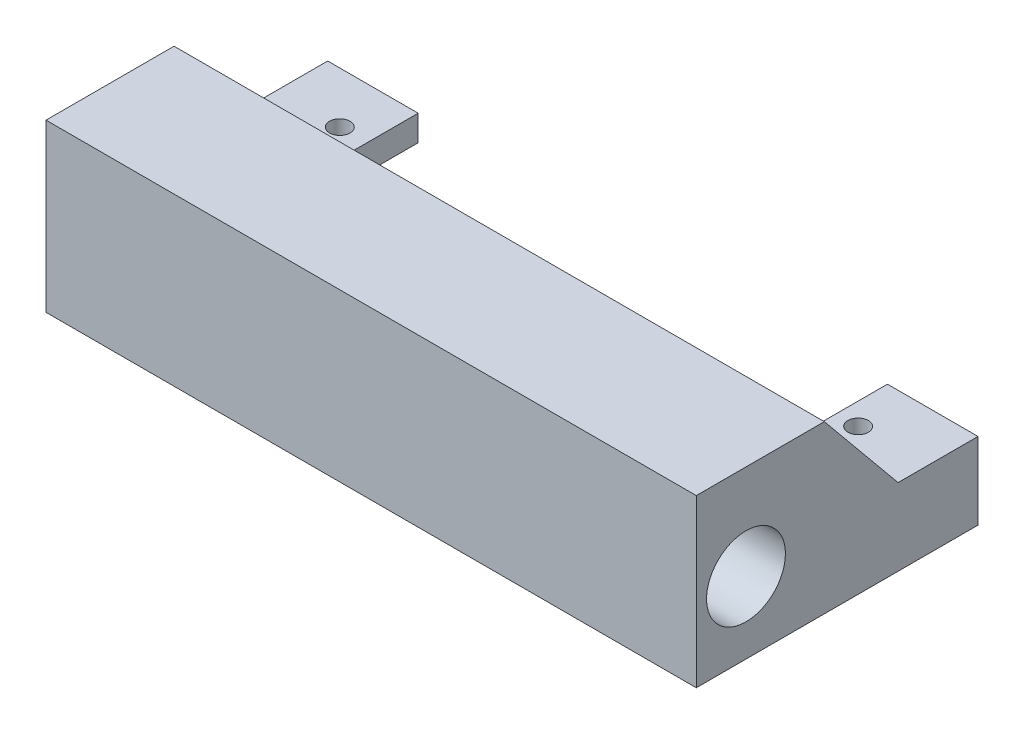
from build123d import *
from build123d.topology import SkipClean

# Parameters (mm, degrees)
SALIENTE_EXTRUIR1_DEPTH  = 5
SALIENTE_EXTRUIR3_DEPTH  = 5
SALIENTE_EXTRUIR4_DEPTH  = 12.5
CROQUIS2_W               = 12.6
CROQUIS2_H               = 5
CORTAR_EXTRUIR1_DEPTH    = 127.5
CROQUIS3_W               = 4.8
CROQUIS3_H               = 5
CORTAR_EXTRUIR2_DEPTH    = 255
CROQUIS4_W               = 116.76
CROQUIS4_H               = 32.5
SALIENTE_EXTRUIR5_DEPTH  = 25
CROQUIS5_R               = 4.5
CORTAR_EXTRUIR3_DEPTH    = 155
CROQUIS6_R               = 7.7
CORTAR_EXTRUIR4_DEPTH    = 20.3
CROQUIS7_R               = 7.7
SALIENTE_EXTRUIR6_DEPTH  = 5
CORTAR_EXTRUIR5_DEPTH    = 25.2
CROQUIS9_W               = 1
CROQUIS9_H               = 10
CORTAR_EXTRUIR6_DEPTH    = 4.8
CROQUIS10_W              = 117.76
CROQUIS10_H              = 0.4
CORTAR_EXTRUIR7_DEPTH    = 10
CROQUIS11_R              = 2
CORTAR_EXTRUIR8_DEPTH    = 10
CROQUIS12_W              = 3
CROQUIS12_H              = 7.5
CORTAR_EXTRUIR9_DEPTH    = 220
CORTAR_EXTRUIR10_DEPTH   = 220
SALIENTE_EXTRUIR7_DEPTH  = 16.68
SALIENTE_EXTRUIR8_START  = 1
CROQUIS15_R              = 7.7
SALIENTE_EXTRUIR8_DEPTH  = 1
SALIENTE_EXTRUIR9_START  = 1.8
CROQUIS16_R              = 7.7
CROQUIS16_R_2            = 4.5
SALIENTE_EXTRUIR9_DEPTH  = 1.8
SALIENTE_EXTRUIR10_DEPTH = 1
CROQUIS18_W              = 0.78
CROQUIS18_H              = 5
SALIENTE_EXTRUIR11_DEPTH = 31
SALIENTE_EXTRUIR12_DEPTH = 0.78
CORTAR_EXTRUIR11_DEPTH   = 220.78
CROQUIS21_R              = 2
CORTAR_EXTRUIR12_DEPTH   = 220.78
CROQUIS22_W              = 0.2
CROQUIS22_H              = 10
SALIENTE_EXTRUIR13_DEPTH = 30.78


with BuildPart() as part:
    # Croquis1 → Saliente-Extruir1 (new body)
    with BuildSketch(Plane(origin=(0, 0, 0), x_dir=(1, 0, 0), z_dir=(0, 1, 0))):
        Polygon((-45.7, 25.2), (-58.38, 25.2), (-58.38, -4.8), (58.38, -4.8), (58.38, 25.2), (45.7, 25.2), (45.7, 0), (-45.7, 0), align=None)
    extrude(amount=SALIENTE_EXTRUIR1_DEPTH)

    # Croquis1_4 → Saliente-Extruir3 (add)
    with BuildSketch(Plane(origin=(0, 0, 0), x_dir=(1, 0, 0), z_dir=(0, 1, 0))):
        Polygon((-45.7, 12.6), (-58.38, 12.6), (-58.38, -4.8), (58.38, -4.8), (58.38, 12.6), (45.7, 12.6), (45.7, 0), (-45.7, 0), align=None)
    extrude(amount=-SALIENTE_EXTRUIR3_DEPTH)

    # Croquis1_5 → Saliente-Extruir4 (add)
    with BuildSketch(Plane(origin=(0, 0, 0), x_dir=(1, 0, 0), z_dir=(0, 1, 0))):
        Polygon((-45.7, 12.6), (-58.38, 12.6), (-58.38, -4.8), (58.38, -4.8), (58.38, 12.6), (45.7, 12.6), (45.7, 0), (-45.7, 0), align=None)
    extrude(amount=SALIENTE_EXTRUIR4_DEPTH)

    # Croquis2 → Cortar-Extruir1 (cut, symmetric)
    with BuildSketch(Plane.ZY.offset(-45.7)):
        with Locations((-6.3, -2.5)):
            Rectangle(CROQUIS2_W, CROQUIS2_H)
    extrude(amount=CORTAR_EXTRUIR1_DEPTH, both=True, mode=Mode.SUBTRACT)

    # Croquis3 → Cortar-Extruir2 (cut)
    with BuildSketch(Plane.ZY.offset(58.38)):
        with Locations((2.4, -2.5)):
            Rectangle(CROQUIS3_W, CROQUIS3_H)
    extrude(amount=-CORTAR_EXTRUIR2_DEPTH, mode=Mode.SUBTRACT)

    # Croquis4 → Saliente-Extruir5 (add)
    with BuildSketch(Plane.XY.offset(4.8)):
        with Locations((0, 6.25)):
            Rectangle(CROQUIS4_W, CROQUIS4_H)
    extrude(amount=SALIENTE_EXTRUIR5_DEPTH)

    # Croquis5 → Cortar-Extruir3 (cut)
    with BuildSketch(Plane.ZY.offset(58.38)):
        with Locations((20.1, 4)):
            Circle(CROQUIS5_R)
    extrude(amount=-CORTAR_EXTRUIR3_DEPTH, mode=Mode.SUBTRACT)

    # Croquis6 → Cortar-Extruir4 (cut)
    with BuildSketch(Plane.ZY.offset(58.38)):
        with Locations((20.1, 4)):
            Circle(CROQUIS6_R)
    cortar_extruir4 = extrude(amount=-CORTAR_EXTRUIR4_DEPTH, mode=Mode.SUBTRACT)

    # Simetría1: Cortar-Extruir4 across plane
    add(cortar_extruir4.mirror(Plane(origin=(0, 0, 0), x_dir=(0, 0, 1), z_dir=(1, 0, 0))), mode=Mode.SUBTRACT)

    # Croquis7 → Saliente-Extruir6 (add)
    with BuildSketch(Plane.ZY.offset(58.38)):
        Polygon((-25.2, 5), (-25.2, -10), (29.8, -10), (29.8, 22.5), (4.8, 22.5), (4.8, 12.5), (-12.6, 12.5), (-12.6, 5), align=None)
        with Locations((20.1, 4)):
            Circle(CROQUIS7_R, mode=Mode.SUBTRACT)
    saliente_extruir6 = extrude(amount=SALIENTE_EXTRUIR6_DEPTH)

    # Simetría2: Saliente-Extruir6 across plane
    add(saliente_extruir6.mirror(Plane(origin=(0, 0, 0), x_dir=(0, 0, 1), z_dir=(1, 0, 0))))

    # Croquis8 → Cortar-Extruir5 (cut)
    with BuildSketch(Plane(origin=(0, 0, -25.2), x_dir=(-1, 0, 0), z_dir=(0, 0, -1))):
        Polygon((-58.38, -10), (-59.38, -10), (-59.38, 0), (-58.38, 0), (-46.7, 0), (-46.7, 5), (-46.7, 12.5), (-42.184789705, 12.5), (-42.184789705, -10), align=None)
    extrude(amount=-CORTAR_EXTRUIR5_DEPTH, mode=Mode.SUBTRACT)

    # Croquis9 → Cortar-Extruir6 (cut)
    with BuildSketch(Plane(origin=(0, 0, 0), x_dir=(-1, 0, 0), z_dir=(0, 0, -1))):
        with Locations((-58.88, -5)):
            Rectangle(CROQUIS9_W, CROQUIS9_H)
    extrude(amount=-CORTAR_EXTRUIR6_DEPTH, mode=Mode.SUBTRACT)

    # Croquis10 → Cortar-Extruir7 (cut)
    with BuildSketch(Plane.XZ.offset(10)):
        with Locations((0.5, 5)):
            Rectangle(CROQUIS10_W, CROQUIS10_H)
    extrude(amount=-CORTAR_EXTRUIR7_DEPTH, mode=Mode.SUBTRACT)

    # Croquis11 → Cortar-Extruir8 (cut)
    with BuildSketch(Plane(origin=(0, 5, 0), x_dir=(1, 0, 0), z_dir=(0, 1, 0))):
        with Locations((50.98, 15.2)):
            Circle(CROQUIS11_R)
    extrude(amount=-CORTAR_EXTRUIR8_DEPTH, mode=Mode.SUBTRACT)

    # Croquis12 → Cortar-Extruir9 (cut)
    with BuildSketch(Plane(origin=(63.38, 0, 0), x_dir=(0, 0, -1), z_dir=(1, 0, 0))):
        with Locations((11.1, 8.75)):
            Rectangle(CROQUIS12_W, CROQUIS12_H)
    extrude(amount=-CORTAR_EXTRUIR9_DEPTH, mode=Mode.SUBTRACT)

    # Croquis13 → Cortar-Extruir10 (cut)
    with BuildSketch(Plane(origin=(63.38, 0, 0), x_dir=(0, 0, -1), z_dir=(1, 0, 0))):
        Polygon((9.6, 12.5), (9.6, 5), (-4.8, 22.5), (9.6, 22.5), align=None)
    extrude(amount=-CORTAR_EXTRUIR10_DEPTH, mode=Mode.SUBTRACT)

    # Croquis14 → Saliente-Extruir7 (add)
    with BuildSketch(Plane(origin=(63.38, 0, 0), x_dir=(0, 0, -1), z_dir=(1, 0, 0))):
        Polygon((-4.8, 22.5), (3.428571429, 12.5), (-4.8, 12.5), align=None)
    saliente_extruir7 = extrude(amount=-SALIENTE_EXTRUIR7_DEPTH)

    # Simetría4: Saliente-Extruir7 across plane
    add(saliente_extruir7.mirror(Plane(origin=(0, 0, 0), x_dir=(0, 0, 1), z_dir=(1, 0, 0))))

    # Croquis15 → Saliente-Extruir8 (add)
    with SkipClean():  # the faces are left unmerged after this step: merging them gives an invalid solid
        with BuildSketch(Plane(origin=(63.38, 0, 0), x_dir=(0, 0, -1), z_dir=(1, 0, 0)).offset(SALIENTE_EXTRUIR8_START)):
            Polygon((-29.8, 22.5), (-4.8, 22.5), (9.6, 5), (25.2, 5), (25.2, -10), (-29.8, -10), align=None)
            with Locations((-20.1, 4)):
                Circle(CROQUIS15_R, mode=Mode.SUBTRACT)
        extrude(amount=-SALIENTE_EXTRUIR8_DEPTH)

    # Croquis16 → Saliente-Extruir9 (add)
    with BuildSketch(Plane(origin=(38.08, 0, 0), x_dir=(0, 0, -1), z_dir=(1, 0, 0)).offset(SALIENTE_EXTRUIR9_START)):
        with Locations((-20.1, 4)):
            Circle(CROQUIS16_R)
        with Locations((-20.1, 4)):
            Circle(CROQUIS16_R_2, mode=Mode.SUBTRACT)
    extrude(amount=-SALIENTE_EXTRUIR9_DEPTH)

    # Croquis17 → Saliente-Extruir10 (add)
    with BuildSketch(Plane(origin=(-46.7, 0, 0), x_dir=(0, 0, -1), z_dir=(1, 0, 0))):
        Polygon((-4.8, 12.5), (3.428571429, 12.5), (-4.8, 22.5), align=None)
    extrude(amount=SALIENTE_EXTRUIR10_DEPTH)

    # Croquis18 → Saliente-Extruir11 (add)
    with BuildSketch(Plane(origin=(0, 0, -25.2), x_dir=(-1, 0, 0), z_dir=(0, 0, -1))):
        with Locations((45.31, 2.5)):
            Rectangle(CROQUIS18_W, CROQUIS18_H)
    extrude(amount=-SALIENTE_EXTRUIR11_DEPTH)

    # Croquis19 → Saliente-Extruir12 (add)
    with BuildSketch(Plane(origin=(-45.7, 0, 0), x_dir=(0, 0, -1), z_dir=(1, 0, 0))):
        Polygon((0, 5), (9.6, 5), (-4.8, 22.5), (-4.8, 12.5), (0, 12.5), align=None)
    extrude(amount=SALIENTE_EXTRUIR12_DEPTH)

    # Croquis20 → Cortar-Extruir11 (cut)
    with BuildSketch(Plane(origin=(0, 0, -25.2), x_dir=(-1, 0, 0), z_dir=(0, 0, -1))):
        Polygon((63.38, -10), (62.58, -10), (62.58, 24.783084916), (64.574370111, 24.783084916), (64.574370111, -10), align=None)
    extrude(amount=-CORTAR_EXTRUIR11_DEPTH, mode=Mode.SUBTRACT)

    # Croquis21 → Cortar-Extruir12 (cut)
    with BuildSketch(Plane(origin=(0, 5, 0), x_dir=(1, 0, 0), z_dir=(0, 1, 0))):
        with Locations((-50.22, 15.2)):
            Circle(CROQUIS21_R)
    extrude(amount=-CORTAR_EXTRUIR12_DEPTH, mode=Mode.SUBTRACT)

    # Croquis22 → Saliente-Extruir13 (add)
    with BuildSketch(Plane(origin=(0, 0, -25.2), x_dir=(-1, 0, 0), z_dir=(0, 0, -1))):
        with Locations((-59.28, -5)):
            Rectangle(CROQUIS22_W, CROQUIS22_H)
    extrude(amount=-SALIENTE_EXTRUIR13_DEPTH)


solid = part.part
